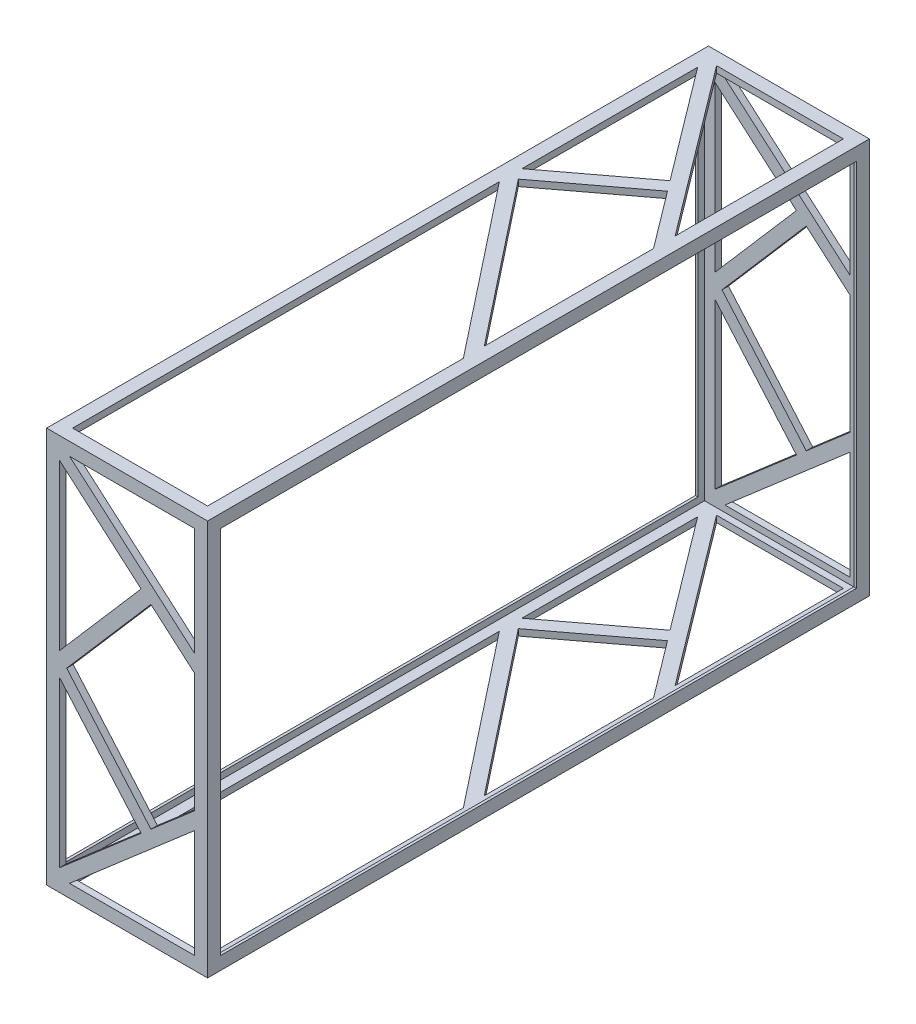
from build123d import *

# Parameters (mm, degrees)
SKETCH1_W           = 510
SKETCH1_H           = 305
SKETCH1_W_2         = 500
SKETCH1_H_2         = 295
BOSS_EXTRUDE1_DEPTH = 120
SKETCH2_W           = 510
SKETCH2_H           = 305
BOSS_EXTRUDE2_DEPTH = 2
SKETCH3_W           = 510
SKETCH3_H           = 305
BOSS_EXTRUDE3_DEPTH = 2
CUT_EXTRUDE1_DEPTH  = 306
SKETCH5_W           = 490
SKETCH5_H           = 285
CUT_EXTRUDE4_DEPTH  = 125
CUT_EXTRUDE5_DEPTH  = 511


with BuildPart() as part:
    # Sketch1 → Boss-Extrude1 (new body)
    with BuildSketch(Plane(origin=(0, 0, 0), x_dir=(0, 0, -1), z_dir=(1, 0, 0))):
        with Locations((250, 147.5)):
            Rectangle(SKETCH1_W, SKETCH1_H)
        with Locations((250, 147.5)):
            Rectangle(SKETCH1_W_2, SKETCH1_H_2, mode=Mode.SUBTRACT)
    extrude(amount=BOSS_EXTRUDE1_DEPTH)

    # Sketch2 → Boss-Extrude2 (add)
    with BuildSketch(Plane(origin=(120, 0, 0), x_dir=(0, 0, -1), z_dir=(1, 0, 0))):
        with Locations((250, 147.5)):
            Rectangle(SKETCH2_W, SKETCH2_H)
    extrude(amount=BOSS_EXTRUDE2_DEPTH)

    # Sketch3 → Boss-Extrude3 (add)
    with BuildSketch(Plane.ZY):
        with Locations((-250, 147.5)):
            Rectangle(SKETCH3_W, SKETCH3_H)
    extrude(amount=BOSS_EXTRUDE3_DEPTH)

    # Sketch4 → Cut-Extrude1 (cut, through all)
    with BuildSketch(Plane.XZ.offset(5)):
        Polygon((14.260678291, -495), (112, -365.295539257), (112, -495), align=None)
        Polygon((73.092374529, -400.311300748), (8, -351.260678291), (8, -486.691799294), align=None)
        Polygon((79.110524761, -392.324945648), (112, -348.679137846), (112, -218.265533068), (13.582159118, -342.945780321), align=None)
        Polygon((8, -333.877817445), (112, -202.125834287), (112, -5), (8, -5), align=None)
    extrude(amount=-CUT_EXTRUDE1_DEPTH, mode=Mode.SUBTRACT)

    # Sketch5 → Cut-Extrude4 (cut, through all)
    with BuildSketch(Plane.ZY.offset(2)):
        with Locations((-250, 147.5)):
            Rectangle(SKETCH5_W, SKETCH5_H)
    extrude(amount=-CUT_EXTRUDE4_DEPTH, mode=Mode.SUBTRACT)

    # Sketch8 → Cut-Extrude5 (cut, through all)
    with BuildSketch(Plane.XY.offset(5)):
        Polygon((15.640858332, 5), (112, 88.387718751), (112, 5), align=None)
        Polygon((70.792299268, 65.951771), (8, 138.511761264), (8, 11.612281249), align=None)
        Polygon((78.353986092, 222.504461556), (112, 193.387718751), (112, 101.612281249), (78.353986092, 72.495538444), (13.446278977, 147.5), align=None)
        Polygon((70.792299268, 229.048229), (8, 156.488238736), (8, 283.387718751), align=None)
        Polygon((15.640858332, 290), (112, 206.612281249), (112, 290), align=None)
    extrude(amount=-CUT_EXTRUDE5_DEPTH, mode=Mode.SUBTRACT)


solid = part.part
